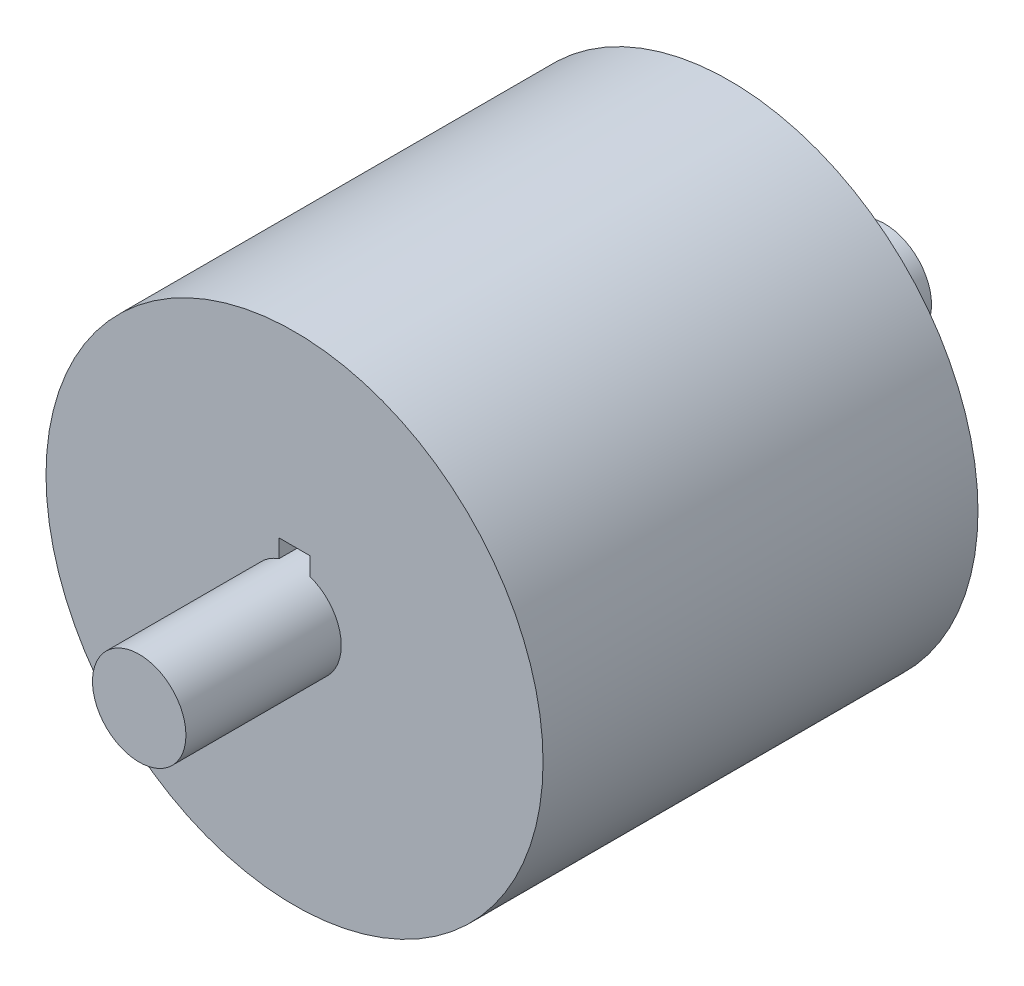
from build123d import *

# Parameters (mm, degrees)
SKETCH1_R           = 12.7
EXTRUDE1_DEPTH      = 11.1125
EXTRUDE2_DEPTH      = 23.225
SKETCH4_R           = 2.3876
BOSS_EXTRUDE1_DEPTH = 19.05


with BuildPart() as part:
    # Sketch1 → Extrude1 (new body, symmetric)
    with BuildSketch(Plane.XY):
        Circle(SKETCH1_R)
    extrude(amount=EXTRUDE1_DEPTH, both=True)

    # Sketch2 → Extrude2 (cut, through all)
    with BuildSketch(Plane.XY.offset(11.1125)):
        with BuildLine():
            ThreePointArc((0.79375, 2.24506403), (0, 2.38125), (-0.79375, 2.24506403))
            Line((-0.79375, 2.24506403), (-0.79375, 1.5875))
            Line((-0.79375, 1.5875), (0.79375, 1.5875))
            Line((0.79375, 1.5875), (0.79375, 2.24506403))
        make_face()
        with BuildLine():
            Line((-0.79375, 1.5875), (-0.79375, 2.24506403))
            ThreePointArc((-0.79375, 2.24506403), (-1.374815329, -1.944282483), (2.38125, 0))
            ThreePointArc((2.38125, 0), (1.944282483, 1.374815329), (0.79375, 2.24506403))
            Line((0.79375, 2.24506403), (0.79375, 1.5875))
            Line((0.79375, 1.5875), (-0.79375, 1.5875))
        make_face()
        with BuildLine():
            Line((0.79375, 3.175), (-0.79375, 3.175))
            Line((-0.79375, 3.175), (-0.79375, 2.24506403))
            ThreePointArc((-0.79375, 2.24506403), (0, 2.38125), (0.79375, 2.24506403))
            Line((0.79375, 2.24506403), (0.79375, 3.175))
        make_face()
    extrude(amount=-EXTRUDE2_DEPTH, mode=Mode.SUBTRACT)

    # Sketch4 → Boss-Extrude1 (add, symmetric)
    with BuildSketch(Plane.XY):
        Circle(SKETCH4_R)
    extrude(amount=BOSS_EXTRUDE1_DEPTH, both=True)


solid = part.part
